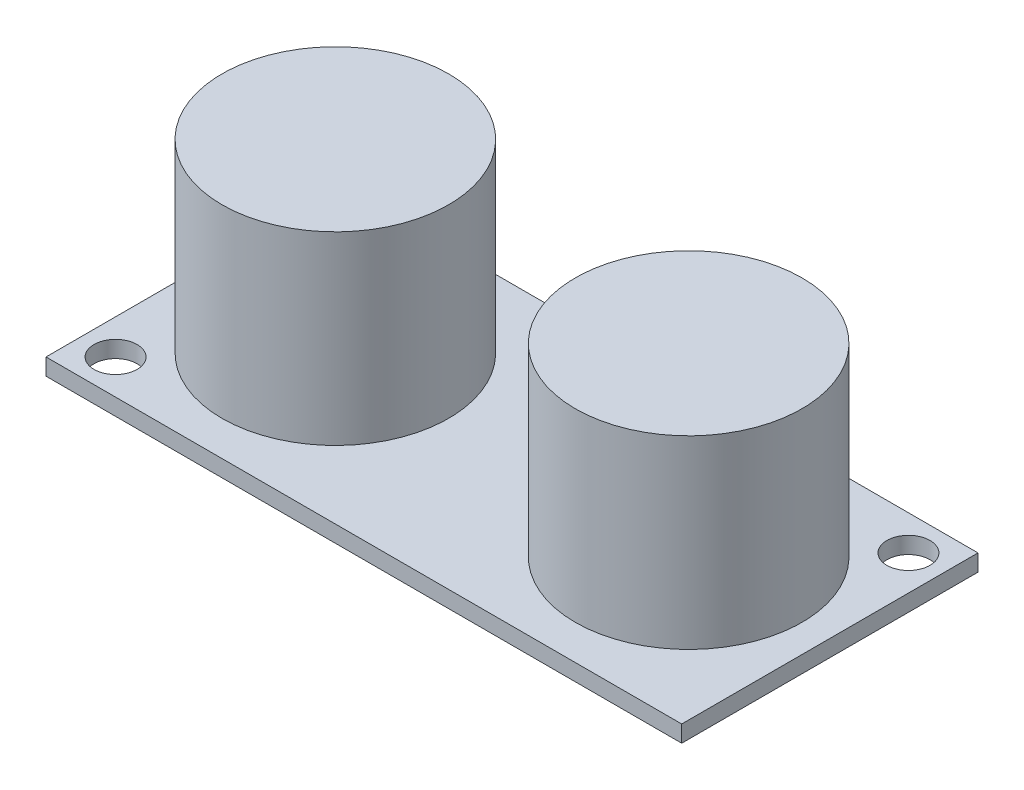
from build123d import *

# Parameters (mm, degrees)
SKETCH1_W           = 45.7
SKETCH1_H           = 21.3
SKETCH1_R           = 1.55
BOSS_EXTRUDE1_DEPTH = 1.2
SKETCH2_R           = 8.15
BOSS_EXTRUDE2_DEPTH = 13.3


with BuildPart() as part:
    # Sketch1 → Boss-Extrude1 (new body)
    with BuildSketch(Plane(origin=(0, 0, 0), x_dir=(1, 0, 0), z_dir=(0, 1, 0))):
        Rectangle(SKETCH1_W, SKETCH1_H)
        with Locations((20.35, 8.15)):
            Circle(SKETCH1_R, mode=Mode.SUBTRACT)
        with Locations((-20.35, -8.15)):
            Circle(SKETCH1_R, mode=Mode.SUBTRACT)
    extrude(amount=BOSS_EXTRUDE1_DEPTH)

    # Sketch2 → Boss-Extrude2 (add)
    with BuildSketch(Plane(origin=(0, 1.2, 0), x_dir=(1, 0, 0), z_dir=(0, 1, 0))):
        with Locations((-12.7, 0)):
            Circle(SKETCH2_R)
        with Locations((12.7, 0)):
            Circle(SKETCH2_R)
    extrude(amount=BOSS_EXTRUDE2_DEPTH)


solid = part.part
